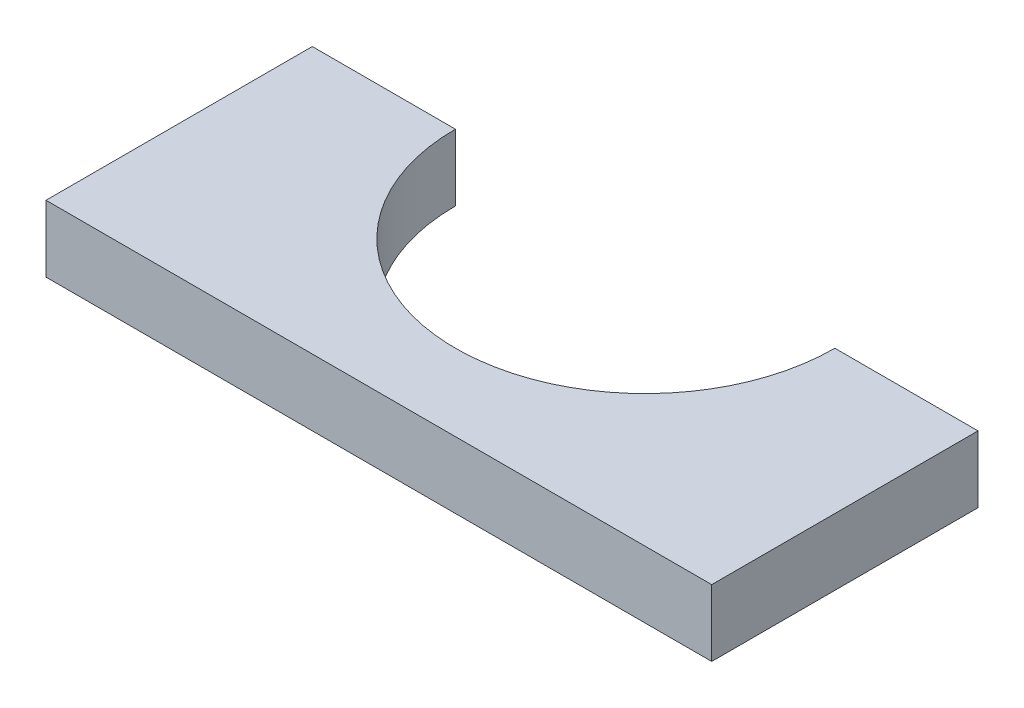
from build123d import *

# Parameters (mm, degrees)
EXTRUDE_1_DEPTH = 20


with BuildPart() as part:
    # Эскиз1 → Бобышка-Вытянуть1 (new body)
    with BuildSketch(Plane(origin=(0, 0, 0), x_dir=(1, 0, 0), z_dir=(0, 1, 0))):
        with BuildLine():
            Line((-100, 0), (100, 0))
            Line((100, 0), (100, 80))
            Line((100, 80), (57, 80))
            ThreePointArc((57, 80), (0, 23), (-57, 80))
            Line((-57, 80), (-100, 80))
            Line((-100, 80), (-100, 0))
        make_face()
    extrude(amount=EXTRUDE_1_DEPTH)


solid = part.part
